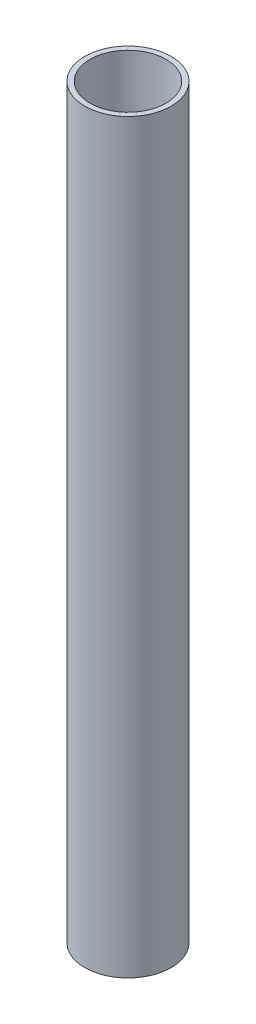
from build123d import *

# Parameters (mm, degrees)
SKETCH1_R           = 25
SKETCH1_R_2         = 22
BOSS_EXTRUDE1_DEPTH = 431.8


with BuildPart() as part:
    # Sketch1 → Boss-Extrude1 (new body)
    with BuildSketch(Plane(origin=(0, 0, 0), x_dir=(1, 0, 0), z_dir=(0, 1, 0))):
        Circle(SKETCH1_R)
        Circle(SKETCH1_R_2, mode=Mode.SUBTRACT)
    extrude(amount=BOSS_EXTRUDE1_DEPTH)


solid = part.part
